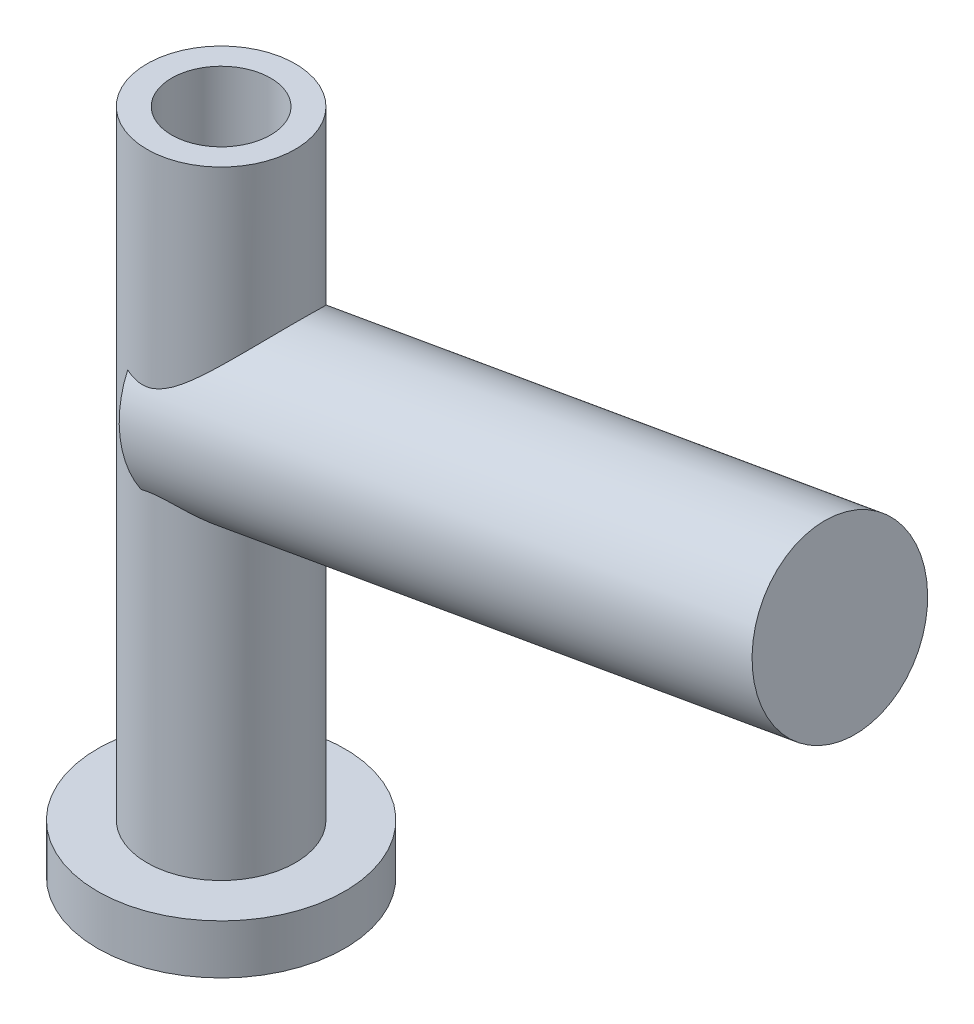
from build123d import *

# Parameters (mm, degrees)
SKETCH3_R           = 35
BOSS_EXTRUDE1_DEPTH = 260
SKETCH4_R           = 20
CUT_EXTRUDE1_DEPTH  = 376.691521045


with BuildPart() as part:
    # Sketch1 → Revolve2 (revolve)
    with BuildSketch(Plane.XY):
        Polygon((0, 135), (0, -135), (50, -135), (50, -115), (30, -115), (30, 135), align=None)
    revolve(axis=Axis((0, 135, 0), (0, -1, 0)))

    # Sketch3 → Boss-Extrude1 (add)
    with BuildSketch(Plane(origin=(0, 0, 0), x_dir=(0, 0, 1), z_dir=(0.9848077530122081, 0.17364817766693041, 0))):
        with Locations((0, -32.949046657)):
            Circle(SKETCH3_R)
    extrude(amount=BOSS_EXTRUDE1_DEPTH)

    # Sketch4 → Cut-Extrude1 (cut, through all)
    with BuildSketch(Plane(origin=(0, 135, 0), x_dir=(1, 0, 0), z_dir=(0, 1, 0))):
        Circle(SKETCH4_R)
    extrude(amount=-CUT_EXTRUDE1_DEPTH, mode=Mode.SUBTRACT)


solid = part.part
